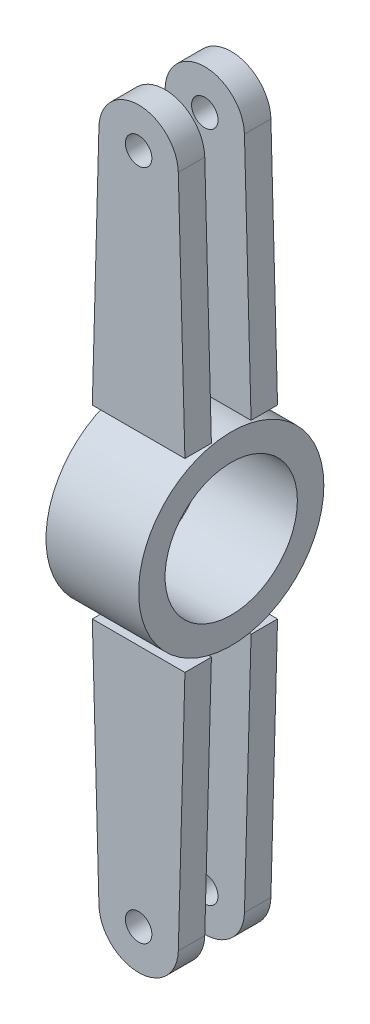
from build123d import *

# Parameters (mm, degrees)
SKETCH1_R             = 35
SKETCH1_R_2           = 25
BOSS_EXTRUDE1_DEPTH   = 17.5
SKETCH5_R             = 5
BOSS_EXTRUDE3_DEPTH   = 10
BOSS_EXTRUDE3_2_DEPTH = 10
SKETCH4_R             = 5
BOSS_EXTRUDE5_DEPTH   = 10
BOSS_EXTRUDE5_2_DEPTH = 10


with BuildPart() as part:
    # Sketch1 → Boss-Extrude1 (new body, symmetric)
    with BuildSketch(Plane(origin=(0, 0, 0), x_dir=(0, 0, -1), z_dir=(1, 0, 0))):
        Circle(SKETCH1_R)
        Circle(SKETCH1_R_2, mode=Mode.SUBTRACT)
    extrude(amount=BOSS_EXTRUDE1_DEPTH, both=True)


with BuildPart() as body_2:
    # Sketch5 → Boss-Extrude3 (new body)
    with BuildSketch(Plane.XY.offset(-7.5)):
        with BuildLine():
            Line((-17.5, -35), (-14.994489274, -127.40656046))
            ThreePointArc((-14.994489274, -127.40656046), (0, -142), (14.994489274, -127.40656046))
            Line((14.994489274, -127.40656046), (17.5, -35))
            Line((17.5, -35), (-17.5, -35))
        make_face()
        with Locations((0, -127)):
            Circle(SKETCH5_R, mode=Mode.SUBTRACT)
    extrude(amount=-BOSS_EXTRUDE3_DEPTH)


with BuildPart() as body_3:
    # Sketch5 → Boss-Extrude3 2 (new body)
    with BuildSketch(Plane.XY.offset(-7.5)):
        with BuildLine():
            Line((-17.5, 35), (17.5, 35))
            Line((17.5, 35), (14.994489274, 127.40656046))
            ThreePointArc((14.994489274, 127.40656046), (0, 142), (-14.994489274, 127.40656046))
            Line((-14.994489274, 127.40656046), (-17.5, 35))
        make_face()
        with Locations((0, 127)):
            Circle(SKETCH5_R, mode=Mode.SUBTRACT)
    extrude(amount=-BOSS_EXTRUDE3_2_DEPTH)


with BuildPart() as body_4:
    # Sketch4 → Boss-Extrude5 (new body)
    with BuildSketch(Plane.XY.offset(7.5)):
        with BuildLine():
            Line((-17.5, -35), (-14.994489274, -127.40656046))
            ThreePointArc((-14.994489274, -127.40656046), (0, -142), (14.994489274, -127.40656046))
            Line((14.994489274, -127.40656046), (17.5, -35))
            Line((17.5, -35), (-17.5, -35))
        make_face()
        with Locations((0, -127)):
            Circle(SKETCH4_R, mode=Mode.SUBTRACT)
    extrude(amount=BOSS_EXTRUDE5_DEPTH)


with BuildPart() as body_5:
    # Sketch4 → Boss-Extrude5 2 (new body)
    with BuildSketch(Plane.XY.offset(7.5)):
        with BuildLine():
            Line((-17.5, 35), (17.5, 35))
            Line((17.5, 35), (14.994489274, 127.40656046))
            ThreePointArc((14.994489274, 127.40656046), (0, 142), (-14.994489274, 127.40656046))
            Line((-14.994489274, 127.40656046), (-17.5, 35))
        make_face()
        with Locations((0, 127)):
            Circle(SKETCH4_R, mode=Mode.SUBTRACT)
    extrude(amount=BOSS_EXTRUDE5_2_DEPTH)


solid = Compound([part.part, body_2.part, body_3.part, body_4.part, body_5.part])
